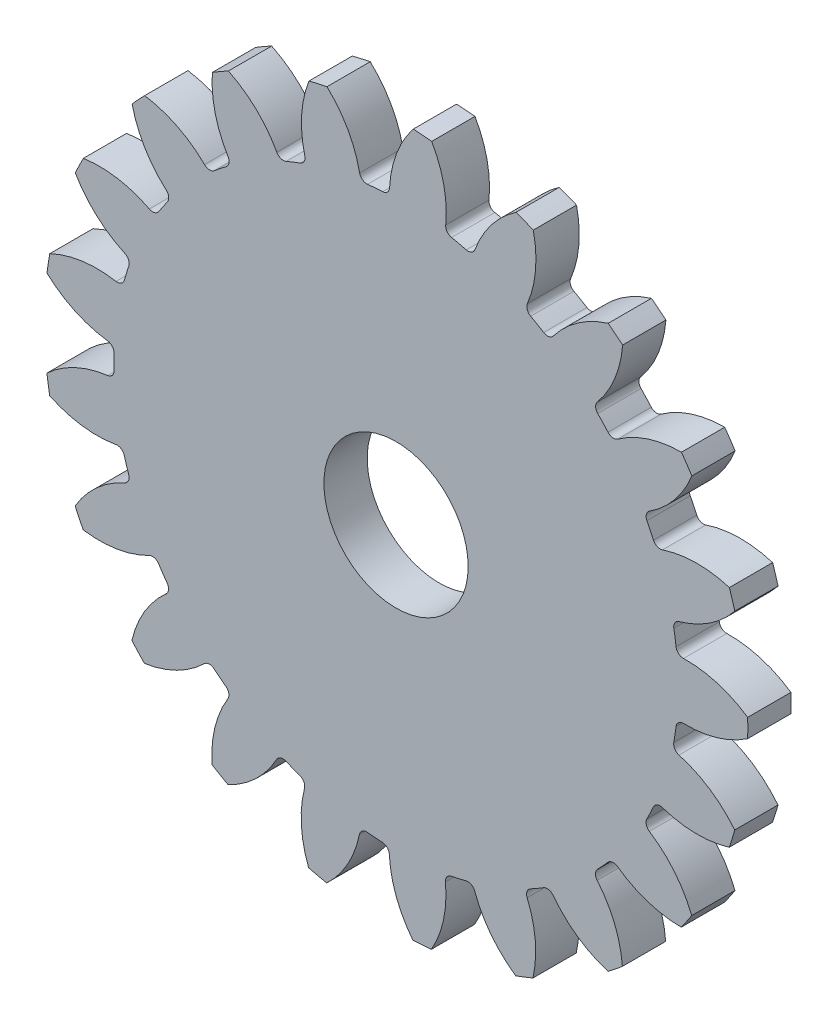
from build123d import *

# Parameters (mm, degrees)
CROQUIS1_R              = 24.384
SALIENTE_EXTRUIR1_DEPTH = 3
CORTAR_EXTRUIR1_DEPTH   = 4
REDONDEO1_R             = 0.508
MATRIZC1_COUNT          = 21
REDONDEO1_OF_MATRIZC1_R = 0.508
CROQUIS3_R              = 5
CORTAR_EXTRUIR2_DEPTH   = 4.0000001


with BuildPart() as part:
    # Croquis1 → Saliente-Extruir1 (new body)
    with BuildSketch(Plane.XY):
        Circle(CROQUIS1_R)
    extrude(amount=SALIENTE_EXTRUIR1_DEPTH)

    # Croquis2 → Cortar-Extruir1 (cut, through all)
    with BuildSketch(Plane.XY.offset(3)):
        with BuildLine():
            ThreePointArc((1.192221855, 24.354836543), (-1.811382857, 24.316626989), (-4.787498744, 23.90939798))
            ThreePointArc((-4.787498744, 23.90939798), (-3.228437054, 21.858531337), (-2.443917832, 19.404706378))
            ThreePointArc((-2.443917832, 19.404706378), (-1.45288, 19.503961231), (-0.458074299, 19.55263491))
            ThreePointArc((-0.458074299, 19.55263491), (-0.045774584, 22.095612748), (1.192221855, 24.354836543))
        make_face()
    cortar_extruir1 = extrude(amount=-CORTAR_EXTRUIR1_DEPTH, mode=Mode.SUBTRACT)

    # Redondeo1
    redondeo1_edges = [part.edges().sort_by_distance(p)[0] for p in [
        (-0.458074299, 19.55263491, 1.5),
        (-2.443917832, 19.404706378, 1.5),
    ]]
    fillet(redondeo1_edges, radius=REDONDEO1_R)

    # MatrizC1: Cortar-Extruir1 ×21 about axis
    matrizc1_axis = Axis((0, 0, 0), (0, 0, 1))
    for i in range(1, MATRIZC1_COUNT):
        add(cortar_extruir1.rotate(matrizc1_axis, i * 360 / MATRIZC1_COUNT), mode=Mode.SUBTRACT)

    # Redondeo1 of MatrizC1
    redondeo1_of_matrizc1_edges = [part.edges().sort_by_distance(p)[0] for p in [
        (-6.200963656, 18.548946432, 1.5),
        (-8.054979033, 17.822252293, 1.5),
        (-11.39287018, 15.897102663, 1.5),
        (-12.950319998, 14.656212879, 1.5),
        (-15.572470192, 11.832731558, 1.5),
        (-16.6949682, 10.187904633, 1.5),
        (-18.368387888, 6.716970328, 1.5),
        (-18.956195212, 4.814356352, 1.5),
        (-19.532193713, 1.004376807, 1.5),
        (-19.533081092, -0.986968619, 1.5),
        (-18.96047841, -4.797460001, 1.5),
        (-18.374366997, -6.700597096, 1.5),
        (-16.704041394, -10.173021435, 1.5),
        (-15.583009761, -11.818848117, 1.5),
        (-12.963376996, -14.64466527, 1.5),
        (-11.407033721, -15.886942616, 1.5),
        (-8.070859662, -17.815066329, 1.5),
        (-6.217492677, -18.543412545, 1.5),
        (-2.46121103, -19.402520565, 1.5),
        (-0.475500124, -19.552218893, 1.5),
        (3.367127004, -19.265975702, 1.5),
        (5.308742702, -18.823724789, 1.5),
        (8.896281027, -17.41756435, 1.5),
        (10.621280442, -16.422660131, 1.5),
        (13.63496144, -14.02152597, 1.5),
        (14.990070805, -12.56237005, 1.5),
        (17.162115693, -9.379613476, 1.5),
        (18.026927593, -7.585858262, 1.5),
        (19.164340652, -3.904281162, 1.5),
        (19.462012754, -1.935309677, 1.5),
        (19.463729842, 1.917963667, 1.5),
        (19.167812675, 3.887199666, 1.5),
        (18.033681221, 7.569789007, 1.5),
        (17.170468323, 9.36431426, 1.5),
        (15.001260884, 12.549005374, 1.5),
        (13.64745251, 14.009368437, 1.5),
        (10.635912686, 16.413187543, 1.5),
        (8.91180065, 17.409628749, 1.5),
        (5.32551697, 18.818985972, 1.5),
        (3.384296193, 19.262967146, 1.5),
    ]]
    fillet(redondeo1_of_matrizc1_edges, radius=REDONDEO1_OF_MATRIZC1_R)

    # Croquis3 → Cortar-Extruir2 (cut, through all)
    with BuildSketch(Plane.XY.offset(3)):
        Circle(CROQUIS3_R)
    extrude(amount=-CORTAR_EXTRUIR2_DEPTH, mode=Mode.SUBTRACT)


solid = part.part
